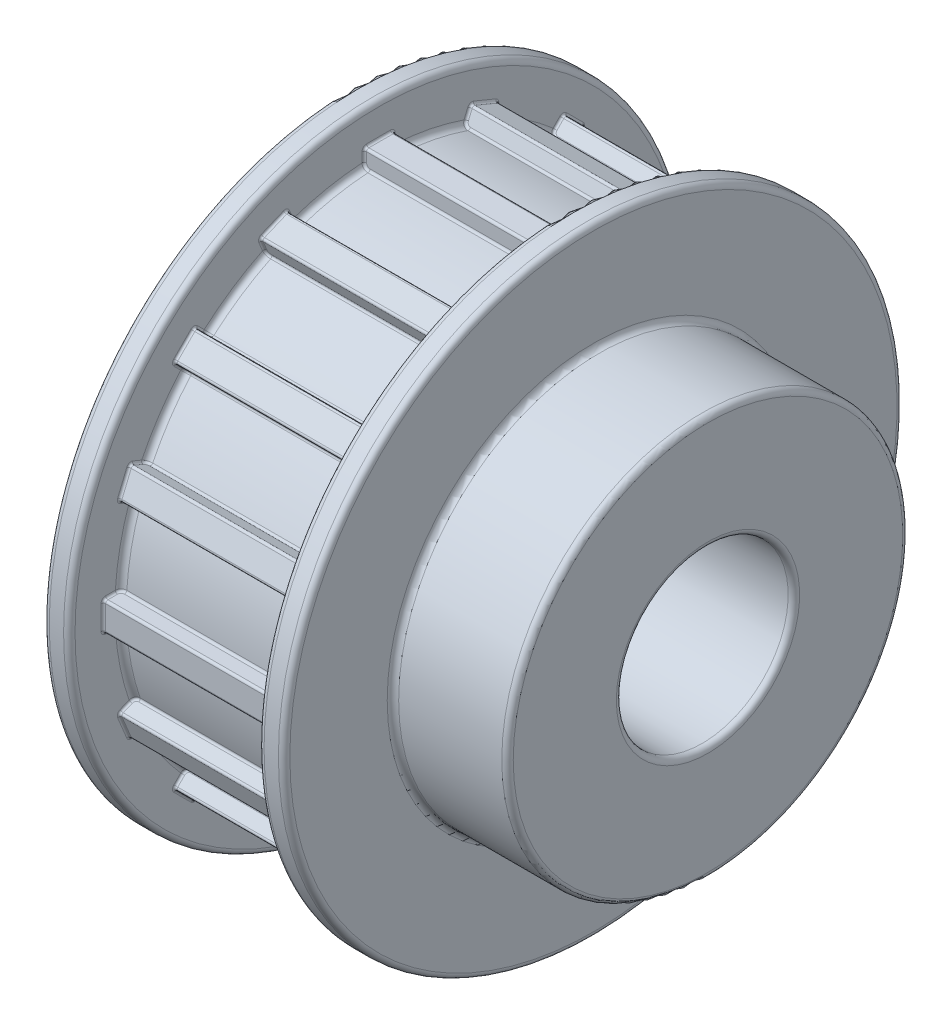
from build123d import *

# Parameters (mm, degrees)
FILLET1_R           = 0.5
SKETCH3_W           = 2.5
SKETCH3_H           = 3
SKETCH3_W_2         = 3
SKETCH3_H_2         = 2.5
BOSS_EXTRUDE2_DEPTH = 16.5
FILLET2_R           = 0.2


with BuildPart() as part:
    # Sketch1 → Revolve1 (revolve)
    with BuildSketch(Plane.XY):
        Polygon((0, 7.5), (31, 7.5), (31, 17.5), (21, 17.5), (21, 27), (18.75, 27), (18.75, 22.525), (2.25, 22.525), (2.25, 27), (0, 27), align=None)
    revolve(axis=Axis((-1179.088726353, 0, 0), (1, 0, 0)))

    # Fillet1
    fillet1_edges = [part.edges().sort_by_distance(p)[0] for p in [
        (31, -17.5, 0),
        (31, -7.5, 0),
        (0, -7.5, 0),
        (0, -27, 0),
        (2.25, -27, 0),
        (2.25, -22.525, 0),
        (18.75, -22.525, 0),
        (18.75, -27, 0),
        (21, -27, 0),
        (21, -17.5, 0),
    ]]
    fillet(fillet1_edges, radius=FILLET1_R)

    # Sketch3 → Boss-Extrude2 (add)
    with BuildSketch(Plane.ZY.offset(-2.25)):
        Polygon((-9.200768581, 18.946212881), (-10.348818878, 21.717851478), (-8.039120047, 22.674560059), (-6.89106975, 19.902921462), align=None)
        with Locations((0, 22.525)):
            Rectangle(SKETCH3_W, SKETCH3_H)
        Polygon((6.89106975, 19.902921462), (8.039120047, 22.674560059), (10.348818878, 21.717851478), (9.200768581, 18.946212881), align=None)
        Polygon((13.983036598, 15.750803551), (16.104356942, 17.872123894), (17.872123894, 16.104356942), (15.750803551, 13.983036598), align=None)
        Polygon((18.946212881, 9.200768581), (21.717851478, 10.348818878), (22.674560059, 8.039120047), (19.902921462, 6.89106975), align=None)
        Polygon((19.902921462, -6.89106975), (22.674560059, -8.039120047), (21.717851478, -10.348818878), (18.946212881, -9.200768581), align=None)
        Polygon((15.750803551, -13.983036598), (17.872123894, -16.104356942), (16.104356942, -17.872123894), (13.983036598, -15.750803551), align=None)
        Polygon((9.200768581, -18.946212881), (10.348818878, -21.717851478), (8.039120047, -22.674560059), (6.89106975, -19.902921462), align=None)
        with Locations((0, -22.525)):
            Rectangle(SKETCH3_W, SKETCH3_H)
        Polygon((-6.89106975, -19.902921462), (-8.039120047, -22.674560059), (-10.348818878, -21.717851478), (-9.200768581, -18.946212881), align=None)
        Polygon((-13.983036598, -15.750803551), (-16.104356942, -17.872123894), (-17.872123894, -16.104356942), (-15.750803551, -13.983036598), align=None)
        Polygon((-18.946212881, -9.200768581), (-21.717851478, -10.348818878), (-22.674560059, -8.039120047), (-19.902921462, -6.89106975), align=None)
        with Locations((-22.525, 0)):
            Rectangle(SKETCH3_W_2, SKETCH3_H_2)
        Polygon((-15.750803551, 13.983036598), (-17.872123894, 16.104356942), (-16.104356942, 17.872123894), (-13.983036598, 15.750803551), align=None)
        Polygon((-19.902921462, 6.89106975), (-22.674560059, 8.039120047), (-21.717851478, 10.348818878), (-18.946212881, 9.200768581), align=None)
        with Locations((22.525, 0)):
            Rectangle(SKETCH3_W_2, SKETCH3_H_2)
    extrude(amount=-BOSS_EXTRUDE2_DEPTH)

    # Fillet2
    fillet2_edges = [part.edges().sort_by_distance(p)[0] for p in [
        (10.4999997, 21.256672506, 7.451811792),
        (2.396315085, 21.392300736, 7.507990845),
        (2.25, 22.196934875, 7.841281218),
        (18.75, 21.240226294, 10.150980049),
        (10.5, 21.717851478, 10.348818878),
        (18.75, 22.196205769, 9.193969463),
        (10.5, 22.674560059, 8.039120047),
        (10.4999997, 20.299963925, 9.761510624),
        (2.396315085, 20.435592155, 9.817689676),
        (18.75, 22.196934875, 7.841281218),
        (2.25, 21.240226294, 10.150980049),
        (2.25, 22.196205769, 9.193969463),
        (18.603684915, 15.122958144, 16.890725097),
        (18.603684915, 16.890725097, 15.122958144),
        (10.4999997, 16.786919743, 15.01915279),
        (2.396315085, 16.890725097, 15.122958144),
        (2.25, 17.506565405, 15.738798452),
        (18.75, 15.738798452, 17.506565405),
        (10.5, 16.104356942, 17.872123894),
        (18.75, 16.988240418, 16.988240418),
        (10.5, 17.872123894, 16.104356942),
        (10.4999997, 15.01915279, 16.786919743),
        (2.396315085, 15.122958144, 16.890725097),
        (18.75, 17.506565405, 15.738798452),
        (2.25, 15.738798452, 17.506565405),
        (2.25, 16.988240418, 16.988240418),
        (18.603684915, 7.507990845, 21.392300736),
        (18.603684915, 9.817689676, 20.435592155),
        (10.4999997, 9.761510624, 20.299963925),
        (2.396315085, 9.817689676, 20.435592155),
        (2.25, 10.150980049, 21.240226294),
        (18.75, 7.841281218, 22.196934875),
        (10.5, 8.039120047, 22.674560059),
        (18.75, 9.193969463, 22.196205769),
        (10.5, 10.348818878, 21.717851478),
        (10.4999997, 7.451811792, 21.256672506),
        (2.396315085, 7.507990845, 21.392300736),
        (18.75, 10.150980049, 21.240226294),
        (2.25, 7.841281218, 22.196934875),
        (2.25, 9.193969463, 22.196205769),
        (18.603684915, -9.817689676, 20.435592155),
        (18.603684915, -7.507990845, 21.392300736),
        (10.4999997, -7.451811792, 21.256672506),
        (2.396315085, -7.507990845, 21.392300736),
        (2.25, -7.841281218, 22.196934875),
        (18.75, -10.150980049, 21.240226294),
        (10.5, -10.348818878, 21.717851478),
        (18.75, -9.193969463, 22.196205769),
        (10.5, -8.039120047, 22.674560059),
        (10.4999997, -9.761510624, 20.299963925),
        (2.396315085, -9.817689676, 20.435592155),
        (18.75, -7.841281218, 22.196934875),
        (2.25, -10.150980049, 21.240226294),
        (2.25, -9.193969463, 22.196205769),
        (18.603684915, -16.890725097, 15.122958144),
        (18.603684915, -15.122958144, 16.890725097),
        (10.4999997, -15.01915279, 16.786919743),
        (2.396315085, -15.122958144, 16.890725097),
        (2.25, -15.738798452, 17.506565405),
        (18.75, -17.506565405, 15.738798452),
        (10.5, -17.872123894, 16.104356942),
        (18.75, -16.988240418, 16.988240418),
        (10.5, -16.104356942, 17.872123894),
        (10.4999997, -16.786919743, 15.01915279),
        (2.396315085, -16.890725097, 15.122958144),
        (18.75, -15.738798452, 17.506565405),
        (2.25, -17.506565405, 15.738798452),
        (2.25, -16.988240418, 16.988240418),
        (18.603684915, -21.392300736, 7.507990845),
        (18.603684915, -20.435592155, 9.817689676),
        (10.4999997, -20.299963925, 9.761510624),
        (2.396315085, -20.435592155, 9.817689676),
        (2.25, -21.240226294, 10.150980049),
        (18.75, -22.196934875, 7.841281218),
        (10.5, -22.674560059, 8.039120047),
        (18.75, -22.196205769, 9.193969463),
        (10.5, -21.717851478, 10.348818878),
        (10.4999997, -21.256672506, 7.451811792),
        (2.396315085, -21.392300736, 7.507990845),
        (18.75, -21.240226294, 10.150980049),
        (2.25, -22.196934875, 7.841281218),
        (2.25, -22.196205769, 9.193969463),
        (10.5, -24.025, -1.25),
        (10.5, -24.025, 1.25),
        (10.4999997, -22.490289571, 1.25),
        (10.5, -24.025, 1.25),
        (2.25, -23.508022226, 1.25),
        (18.75, -23.508022226, -1.25),
        (10.5, -24.025, -1.25),
        (18.75, -24.025, 0),
        (10.5, -24.025, 1.25),
        (10.4999997, -22.490289571, -1.25),
        (10.5, -24.025, -1.25),
        (18.75, -23.508022226, 1.25),
        (2.25, -23.508022226, -1.25),
        (2.25, -24.025, 0),
        (18.603684915, -20.435592155, -9.817689676),
        (18.603684915, -21.392300736, -7.507990845),
        (10.4999997, -21.256672506, -7.451811792),
        (2.396315085, -21.392300736, -7.507990845),
        (2.25, -22.196934875, -7.841281218),
        (18.75, -21.240226294, -10.150980049),
        (10.5, -21.717851478, -10.348818878),
        (18.75, -22.196205769, -9.193969463),
        (10.5, -22.674560059, -8.039120047),
        (10.4999997, -20.299963925, -9.761510624),
        (2.396315085, -20.435592155, -9.817689676),
        (18.75, -22.196934875, -7.841281218),
        (2.25, -21.240226294, -10.150980049),
        (2.25, -22.196205769, -9.193969463),
        (18.603684915, -15.122958144, -16.890725097),
        (18.603684915, -16.890725097, -15.122958144),
        (10.4999997, -16.786919743, -15.01915279),
        (2.396315085, -16.890725097, -15.122958144),
        (2.25, -17.506565405, -15.738798452),
        (18.75, -15.738798452, -17.506565405),
        (10.5, -16.104356942, -17.872123894),
        (18.75, -16.988240418, -16.988240418),
        (10.5, -17.872123894, -16.104356942),
        (10.4999997, -15.01915279, -16.786919743),
        (2.396315085, -15.122958144, -16.890725097),
        (18.75, -17.506565405, -15.738798452),
        (2.25, -15.738798452, -17.506565405),
        (2.25, -16.988240418, -16.988240418),
        (18.603684915, -7.507990845, -21.392300736),
        (18.603684915, -9.817689676, -20.435592155),
        (10.4999997, -9.761510624, -20.299963925),
        (2.396315085, -9.817689676, -20.435592155),
        (2.25, -10.150980049, -21.240226294),
        (18.75, -7.841281218, -22.196934875),
        (10.5, -8.039120047, -22.674560059),
        (18.75, -9.193969463, -22.196205769),
        (10.5, -10.348818878, -21.717851478),
        (10.4999997, -7.451811792, -21.256672506),
        (2.396315085, -7.507990845, -21.392300736),
        (18.75, -10.150980049, -21.240226294),
        (2.25, -7.841281218, -22.196934875),
        (2.25, -9.193969463, -22.196205769),
        (10.5, 1.25, -24.025),
        (10.5, -1.25, -24.025),
        (10.4999997, -1.25, -22.490289571),
        (10.5, -1.25, -24.025),
        (2.25, -1.25, -23.508022226),
        (18.75, 1.25, -23.508022226),
        (10.5, 1.25, -24.025),
        (18.75, 0, -24.025),
        (10.5, -1.25, -24.025),
        (10.4999997, 1.25, -22.490289571),
        (10.5, 1.25, -24.025),
        (18.75, -1.25, -23.508022226),
        (2.25, 1.25, -23.508022226),
        (2.25, 0, -24.025),
        (18.603684915, 16.890725097, -15.122958144),
        (18.603684915, 15.122958144, -16.890725097),
        (10.4999997, 15.01915279, -16.786919743),
        (2.396315085, 15.122958144, -16.890725097),
        (2.25, 15.738798452, -17.506565405),
        (18.75, 17.506565405, -15.738798452),
        (10.5, 17.872123894, -16.104356942),
        (18.75, 16.988240418, -16.988240418),
        (10.5, 16.104356942, -17.872123894),
        (10.4999997, 16.786919743, -15.01915279),
        (2.396315085, 16.890725097, -15.122958144),
        (18.75, 15.738798452, -17.506565405),
        (2.25, 17.506565405, -15.738798452),
        (2.25, 16.988240418, -16.988240418),
        (18.603684915, 9.817689676, -20.435592155),
        (18.603684915, 7.507990845, -21.392300736),
        (10.4999997, 7.451811792, -21.256672506),
        (2.396315085, 7.507990845, -21.392300736),
        (2.25, 7.841281218, -22.196934875),
        (18.75, 10.150980049, -21.240226294),
        (10.5, 10.348818878, -21.717851478),
        (18.75, 9.193969463, -22.196205769),
        (10.5, 8.039120047, -22.674560059),
        (10.4999997, 9.761510624, -20.299963925),
        (2.396315085, 9.817689676, -20.435592155),
        (18.75, 7.841281218, -22.196934875),
        (2.25, 10.150980049, -21.240226294),
        (2.25, 9.193969463, -22.196205769),
        (10.5, -1.25, 24.025),
        (10.5, 1.25, 24.025),
        (10.4999997, 1.25, 22.490289571),
        (10.5, 1.25, 24.025),
        (2.25, 1.25, 23.508022226),
        (18.75, -1.25, 23.508022226),
        (10.5, -1.25, 24.025),
        (18.75, 0, 24.025),
        (10.5, 1.25, 24.025),
        (10.4999997, -1.25, 22.490289571),
        (10.5, -1.25, 24.025),
        (18.75, 1.25, 23.508022226),
        (2.25, -1.25, 23.508022226),
        (2.25, 0, 24.025),
        (18.603684915, 21.392300736, -7.507990845),
        (18.603684915, 20.435592155, -9.817689676),
        (10.4999997, 20.299963925, -9.761510624),
        (2.396315085, 20.435592155, -9.817689676),
        (2.25, 21.240226294, -10.150980049),
        (18.75, 22.196934875, -7.841281218),
        (10.5, 22.674560059, -8.039120047),
        (18.75, 22.196205769, -9.193969463),
        (10.5, 21.717851478, -10.348818878),
        (10.4999997, 21.256672506, -7.451811792),
        (2.396315085, 21.392300736, -7.507990845),
        (18.75, 21.240226294, -10.150980049),
        (2.25, 22.196934875, -7.841281218),
        (2.25, 22.196205769, -9.193969463),
        (10.5, 24.025, 1.25),
        (10.5, 24.025, -1.25),
        (10.4999997, 22.490289571, -1.25),
        (10.5, 24.025, -1.25),
        (2.25, 23.508022226, -1.25),
        (18.75, 23.508022226, 1.25),
        (10.5, 24.025, 1.25),
        (18.75, 24.025, 0),
        (10.5, 24.025, -1.25),
        (10.4999997, 22.490289571, 1.25),
        (10.5, 24.025, 1.25),
        (18.75, 23.508022226, -1.25),
        (2.25, 23.508022226, 1.25),
        (2.25, 24.025, 0),
        (18.603684915, 20.435592155, 9.817689676),
        (18.603684915, 21.392300736, 7.507990845),
    ]]
    fillet(fillet2_edges, radius=FILLET2_R)


solid = part.part
